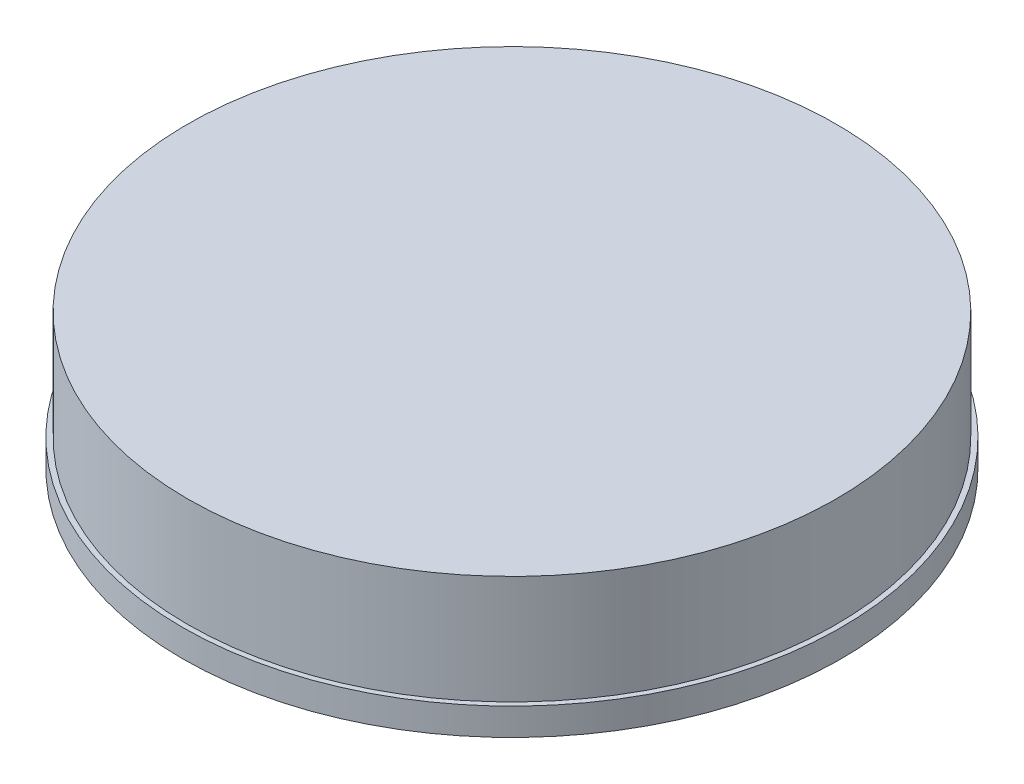
from build123d import *

# Parameters (mm, degrees)
SKETCH1_R           = 9.7
BOSS_EXTRUDE1_DEPTH = 0.8
SKETCH2_R           = 9.55
BOSS_EXTRUDE2_DEPTH = 3.2
SKETCH4_R           = 8.75
CUT_EXTRUDE2_DEPTH  = 3.2


with BuildPart() as part:
    # Sketch1 → Boss-Extrude1 (new body)
    with BuildSketch(Plane(origin=(0, 0, 0), x_dir=(1, 0, 0), z_dir=(0, 1, 0))):
        Circle(SKETCH1_R)
    extrude(amount=BOSS_EXTRUDE1_DEPTH)

    # Sketch2 → Boss-Extrude2 (add)
    with BuildSketch(Plane(origin=(0, 0.8, 0), x_dir=(1, 0, 0), z_dir=(0, 1, 0))):
        Circle(SKETCH2_R)
    extrude(amount=BOSS_EXTRUDE2_DEPTH)

    # Sketch4 → Cut-Extrude2 (cut)
    with BuildSketch(Plane(origin=(0, 0, 0), x_dir=(-1, 0, 0), z_dir=(0, -1, 0))):
        Circle(SKETCH4_R)
    extrude(amount=-CUT_EXTRUDE2_DEPTH, mode=Mode.SUBTRACT)


solid = part.part
